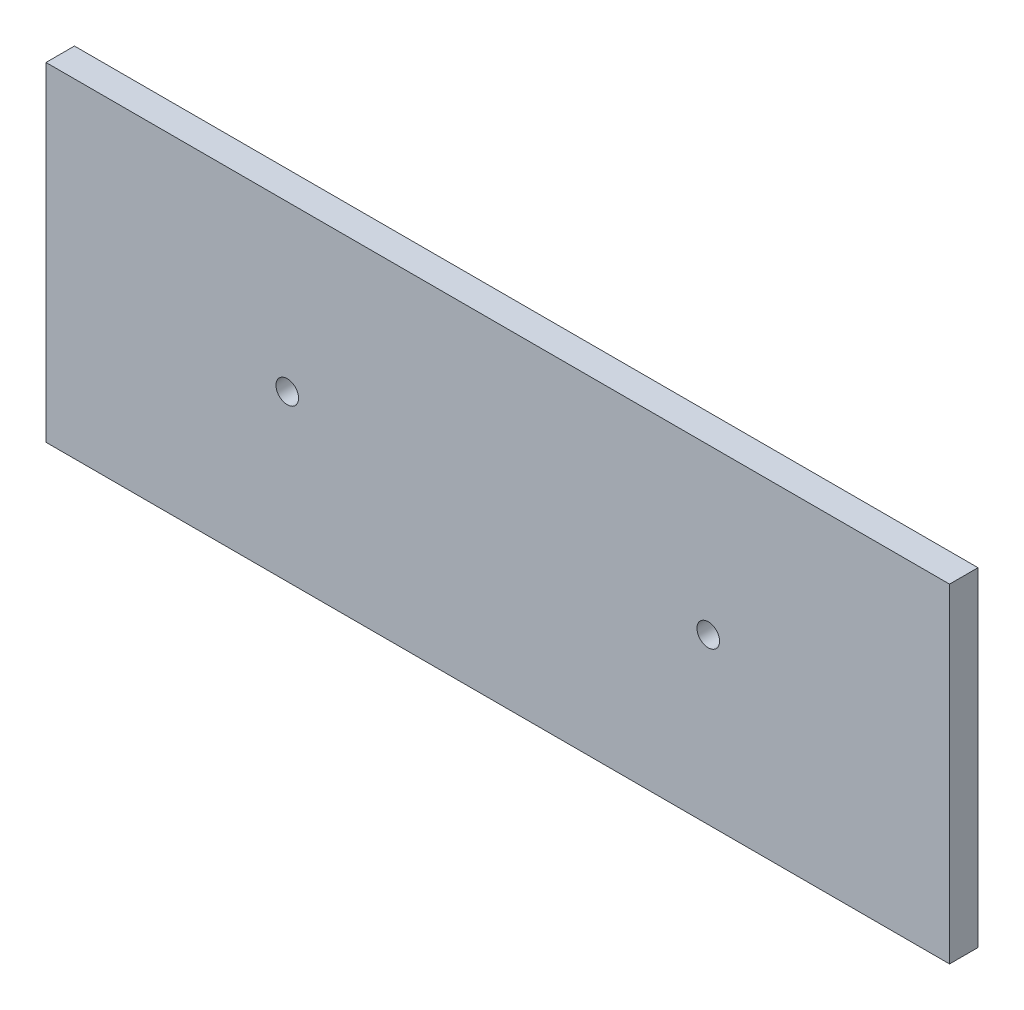
from build123d import *

# Parameters (mm, degrees)
MODEL_W             = 63.5
MODEL_H             = 12.7
MODEL_R             = 0.79375
MODEL_H_2           = 5.209784437
MODEL_H_3           = 5.209784436
BOSS_EXTRUDE1_DEPTH = 2


with BuildPart() as part:
    # Model → Boss-Extrude1 (new body)
    with BuildSketch(Plane.XY):
        with Locations((123.6587005, -17.587063894)):
            Rectangle(MODEL_W, MODEL_H)
        with Locations((108.865320346, -17.587063894)):
            Circle(MODEL_R, mode=Mode.SUBTRACT)
        with Locations((138.452080654, -17.587063894)):
            Circle(MODEL_R, mode=Mode.SUBTRACT)
        with Locations((123.6587005, -8.632171676)):
            Rectangle(MODEL_W, MODEL_H_2)
        with Locations((123.6587005, -26.541956112)):
            Rectangle(MODEL_W, MODEL_H_3)
    extrude(amount=BOSS_EXTRUDE1_DEPTH)


solid = part.part
